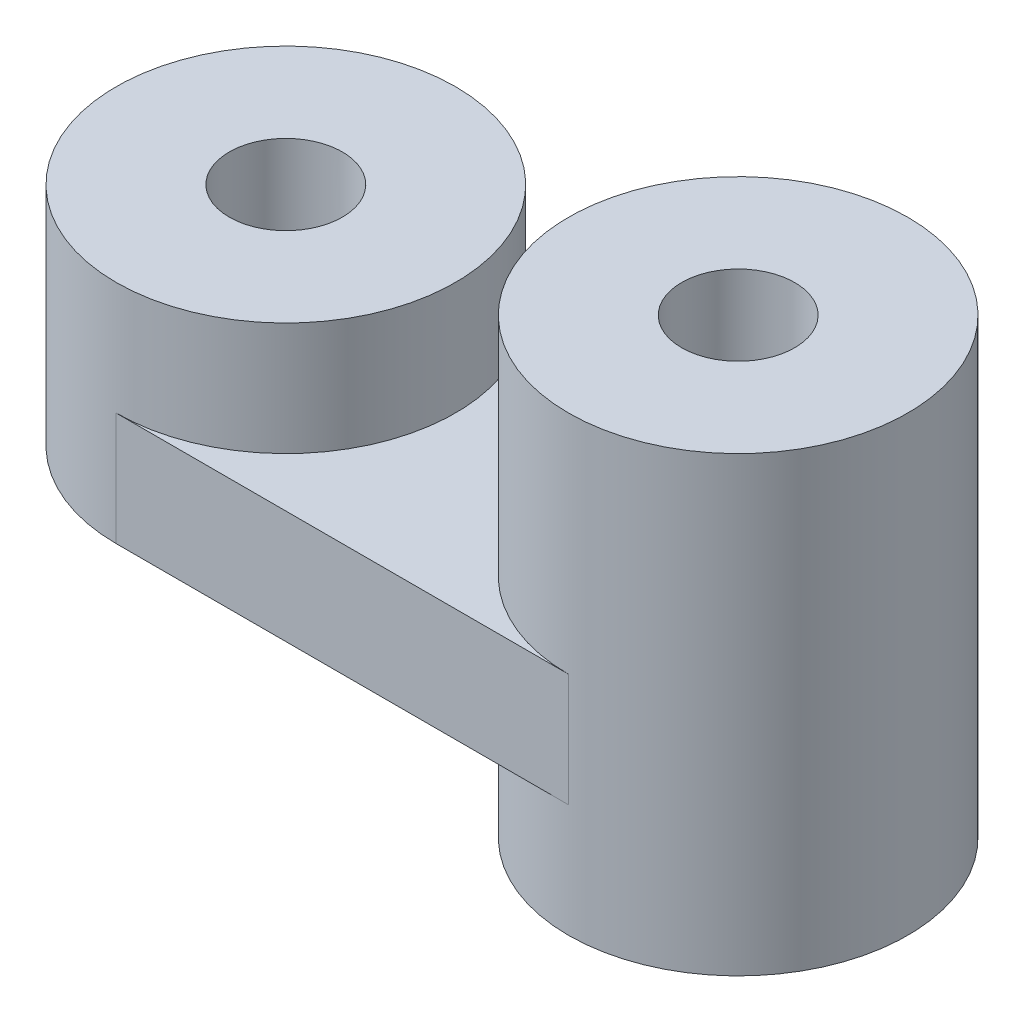
from build123d import *

# Parameters (mm, degrees)
CROQUIS1_R                = 7.5
SALIENTE_EXTRUIR1_DEPTH   = 20
SALIENTE_EXTRUIR1_2_DEPTH = 20
CROQUIS2_W                = 15
CROQUIS2_H                = 5
CORTAR_EXTRUIR1_DEPTH     = 20
CROQUIS3_W                = 15
CROQUIS3_H                = 5
CORTAR_EXTRUIR2_DEPTH     = 20
CROQUIS4_R                = 2.5
CORTAR_EXTRUIR3_DEPTH     = 20
CROQUIS5_R                = 2.5
CORTAR_EXTRUIR4_DEPTH     = 20
CROQUIS6_W                = 20
CROQUIS6_H                = 2.5
EXTRUIR_L_MINA1_DEPTH     = 15


with BuildPart() as part:
    # Croquis1 → Saliente-Extruir1 (new body)
    with BuildSketch(Plane(origin=(0, 0, 0), x_dir=(1, 0, 0), z_dir=(0, 1, 0))):
        with Locations((7.5, -7.5)):
            Circle(CROQUIS1_R)
    extrude(amount=SALIENTE_EXTRUIR1_DEPTH)

    # Croquis5 → Cortar-Extruir4 (cut)
    with BuildSketch(Plane(origin=(0, 20, 0), x_dir=(1, 0, 0), z_dir=(0, 1, 0))):
        with Locations((7.5, -7.5)):
            Circle(CROQUIS5_R)
    extrude(amount=-CORTAR_EXTRUIR4_DEPTH, mode=Mode.SUBTRACT)



with BuildPart() as body_2:
    # Croquis1 → Saliente-Extruir1 2 (new body)
    with BuildSketch(Plane(origin=(0, 0, 0), x_dir=(1, 0, 0), z_dir=(0, 1, 0))):
        with Locations((-12.5, -7.5)):
            Circle(CROQUIS1_R)
    extrude(amount=SALIENTE_EXTRUIR1_2_DEPTH)

    # Croquis2 → Cortar-Extruir1 (cut)
    with BuildSketch(Plane.XY.offset(15)):
        with Locations((-12.5, 2.5)):
            Rectangle(CROQUIS2_W, CROQUIS2_H)
    extrude(amount=-CORTAR_EXTRUIR1_DEPTH, mode=Mode.SUBTRACT)

    # Croquis3 → Cortar-Extruir2 (cut)
    with BuildSketch(Plane.XY.offset(15)):
        with Locations((-12.5, 17.5)):
            Rectangle(CROQUIS3_W, CROQUIS3_H)
    extrude(amount=-CORTAR_EXTRUIR2_DEPTH, mode=Mode.SUBTRACT)

    # Croquis4 → Cortar-Extruir3 (cut)
    with BuildSketch(Plane(origin=(0, 15, 0), x_dir=(1, 0, 0), z_dir=(0, 1, 0))):
        with Locations((-12.5, -7.5)):
            Circle(CROQUIS4_R)
    extrude(amount=-CORTAR_EXTRUIR3_DEPTH, mode=Mode.SUBTRACT)


with BuildPart() as part_1:
    add(part.part)

    add(body_2.part)  # Extruir-Lámina1 merges body 2
    # Croquis6 → Extruir-Lámina1 (add)
    with BuildSketch(Plane.XY.offset(15)):
        with Locations((-2.5, 6.25)):
            Rectangle(CROQUIS6_W, CROQUIS6_H)
        with Locations((-2.5, 8.75)):
            Rectangle(CROQUIS6_W, CROQUIS6_H)
    extrude(amount=-EXTRUIR_L_MINA1_DEPTH)


solid = part_1.part
